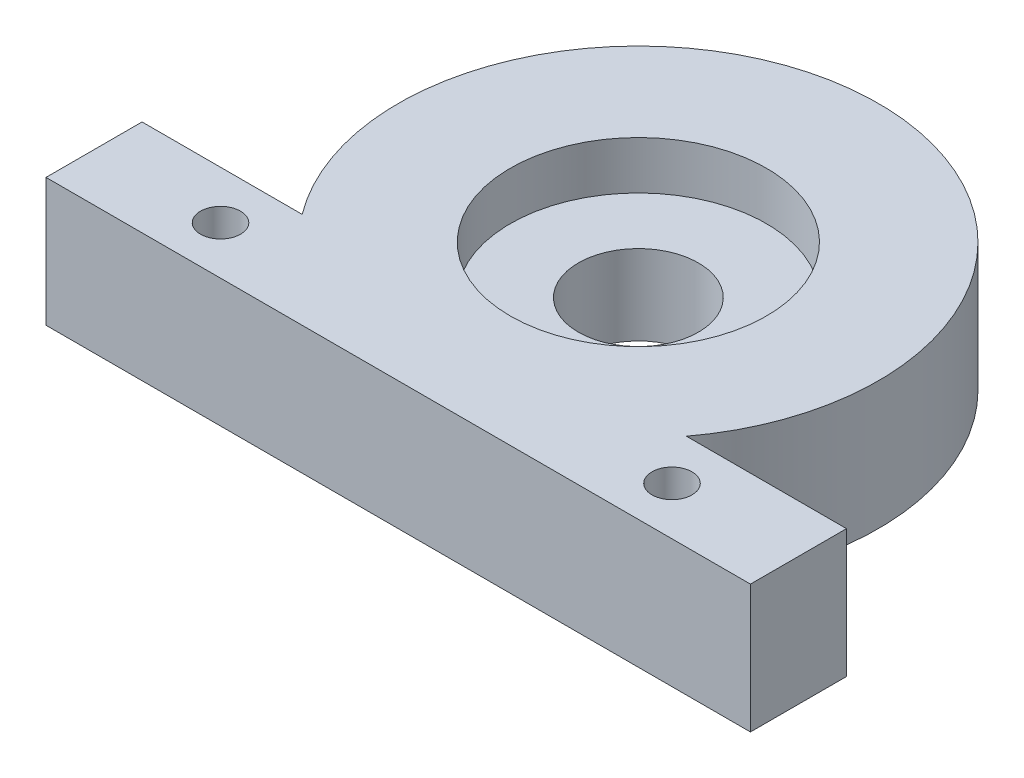
from build123d import *

# Parameters (mm, degrees)
SKETCH1_R           = 0.625
SKETCH1_R_2         = 1.875
BOSS_EXTRUDE1_DEPTH = 4
SKETCH2_R           = 4
CUT_EXTRUDE1_DEPTH  = 1.5


with BuildPart() as part:
    # Sketch1 → Boss-Extrude1 (new body)
    with BuildSketch(Plane(origin=(0, 0, 0), x_dir=(1, 0, 0), z_dir=(0, 1, 0))):
        with BuildLine():
            Line((-6, -4.5), (-11, -4.5))
            Line((-11, -4.5), (-11, -7.5))
            Line((-11, -7.5), (11, -7.5))
            Line((11, -7.5), (11, -4.5))
            Line((11, -4.5), (6, -4.5))
            ThreePointArc((6, -4.5), (0, 7.5), (-6, -4.5))
        make_face()
        with Locations((-7.05, -6)):
            Circle(SKETCH1_R, mode=Mode.SUBTRACT)
        with Locations((7.05, -6)):
            Circle(SKETCH1_R, mode=Mode.SUBTRACT)
        Circle(SKETCH1_R_2, mode=Mode.SUBTRACT)
    extrude(amount=BOSS_EXTRUDE1_DEPTH)

    # Sketch2 → Cut-Extrude1 (cut)
    with BuildSketch(Plane(origin=(0, 4, 0), x_dir=(1, 0, 0), z_dir=(0, 1, 0))):
        Circle(SKETCH2_R)
    extrude(amount=-CUT_EXTRUDE1_DEPTH, mode=Mode.SUBTRACT)


solid = part.part
